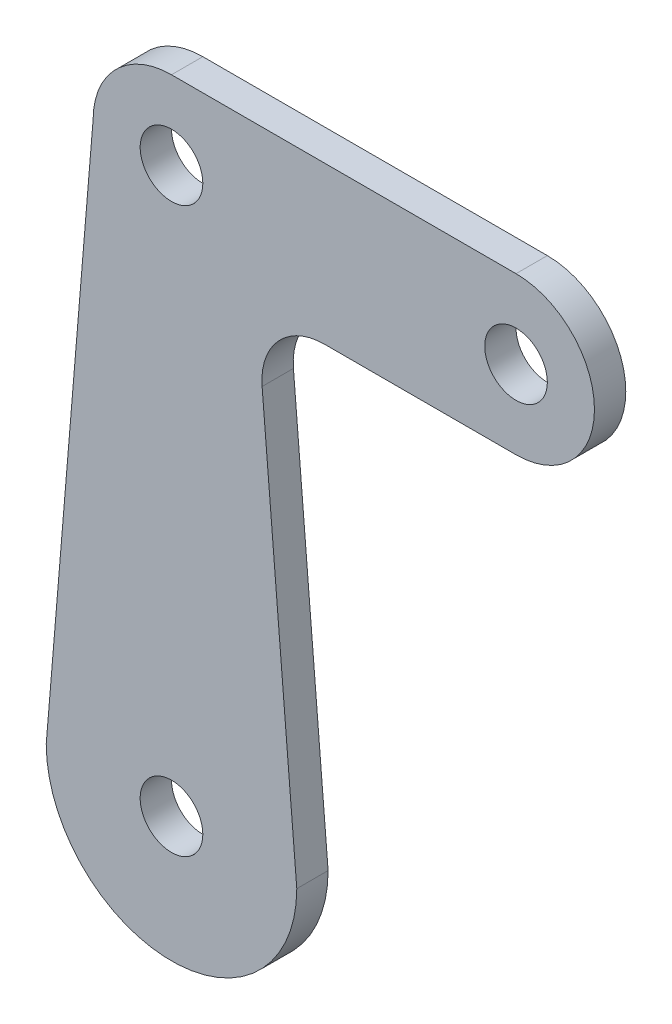
from build123d import *

# Parameters (mm, degrees)
SKETCH1_R           = 3.175
BOSS_EXTRUDE1_DEPTH = 3.175


with BuildPart() as part:
    # Sketch1 → Boss-Extrude1 (new body)
    with BuildSketch(Plane.XY):
        with BuildLine():
            ThreePointArc((0, 7.9502), (-5.621640332, 5.621640332), (-7.9502, 0))
            Line((-7.9502, 0), (-12.525754193, -55.05345954))
            Line((-12.525754193, -55.05345954), (-12.7, -57.15))
            ThreePointArc((-12.7, -57.15), (0, -69.85), (12.7, -57.15))
            Line((12.7, -57.15), (12.525900071, -55.054331273))
            Line((12.525900071, -55.054331273), (9.183881789, -14.825922015))
            ThreePointArc((9.183881789, -14.825922015), (10.839778656, -9.999957844), (15.512081878, -7.9502))
            Line((15.512081878, -7.9502), (34.925, -7.9502))
            ThreePointArc((34.925, -7.9502), (42.8752, 0), (34.925, 7.9502))
            Line((34.925, 7.9502), (0, 7.9502))
        make_face()
        with Locations((0, -57.15)):
            Circle(SKETCH1_R, mode=Mode.SUBTRACT)
        Circle(SKETCH1_R, mode=Mode.SUBTRACT)
        with Locations((34.925, 0)):
            Circle(SKETCH1_R, mode=Mode.SUBTRACT)
    extrude(amount=BOSS_EXTRUDE1_DEPTH)


solid = part.part
